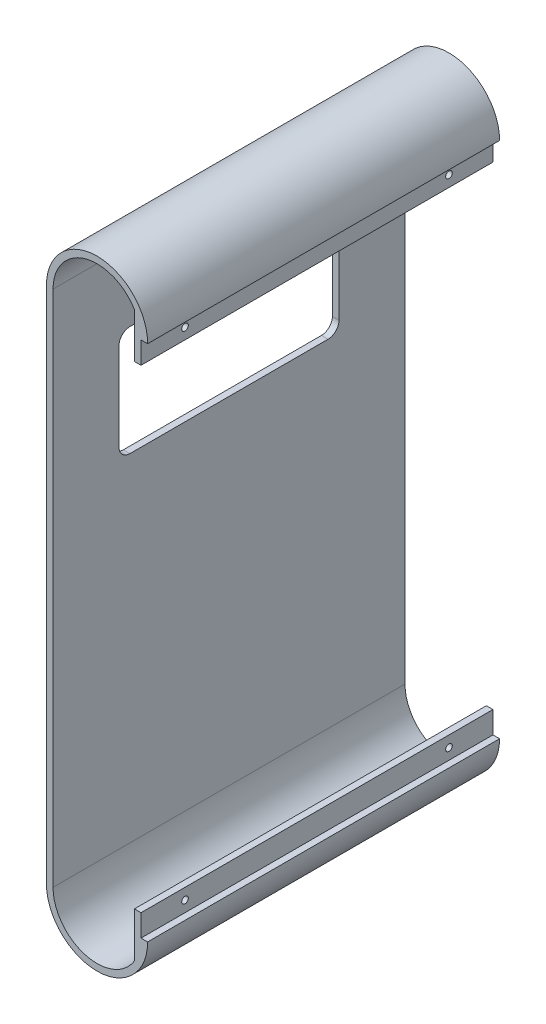
from build123d import *

# Parameters (mm, degrees)
BOSS_EXTRUDE1_DEPTH = 160
SKETCH5_W           = 3
SKETCH5_H           = 21.357816692
BOSS_EXTRUDE4_DEPTH = 160
SKETCH7_R           = 1.5
CUT_EXTRUDE2_DEPTH  = 7
CUT_EXTRUDE3_DEPTH  = 3


with BuildPart() as part:
    # Sketch1 → Boss-Extrude1 (new body)
    with BuildSketch(Plane.XY):
        with BuildLine():
            Line((-40, -75), (-40, 160.5))
            ThreePointArc((-40, 160.5), (-20, 180.5), (0, 160.5))
            Line((0, 160.5), (3, 160.5))
            ThreePointArc((3, 160.5), (-20, 183.5), (-43, 160.5))
            Line((-43, 160.5), (-43, -75))
            ThreePointArc((-43, -75), (-20, -98), (3, -75))
            Line((3, -75), (0, -75))
            ThreePointArc((0, -75), (-20, -95), (-40, -75))
        make_face()
    extrude(amount=-BOSS_EXTRUDE1_DEPTH)

    # Sketch5 → Boss-Extrude4 (add)
    with BuildSketch(Plane(origin=(0, 0, -160), x_dir=(-1, 0, 0), z_dir=(0, 0, -1))):
        with Locations((1.5, -75.678908346)):
            Rectangle(SKETCH5_W, SKETCH5_H)
        with Locations((1.5, 161.178908346)):
            Rectangle(SKETCH5_W, SKETCH5_H)
    extrude(amount=-BOSS_EXTRUDE4_DEPTH)

    # Sketch7 → Cut-Extrude2 (cut, through all)
    with BuildSketch(Plane.ZY.offset(3)):
        with Locations((-140, -70)):
            Circle(SKETCH7_R)
        with Locations((-20, -70)):
            Circle(SKETCH7_R)
        with Locations((-20, 155.5)):
            Circle(SKETCH7_R)
        with Locations((-140, 155.5)):
            Circle(SKETCH7_R)
    extrude(amount=-CUT_EXTRUDE2_DEPTH, mode=Mode.SUBTRACT)

    # Sketch8 → Cut-Extrude3 (cut)
    with BuildSketch(Plane.ZY.offset(43)):
        with BuildLine():
            Line((-125, 128.257283518), (-35, 128.257283518))
            ThreePointArc((-35, 128.257283518), (-31.464466094, 126.792817424), (-30, 123.257283518))
            Line((-30, 123.257283518), (-30, 83.257283518))
            ThreePointArc((-30, 83.257283518), (-31.464466094, 79.721749612), (-35, 78.257283518))
            Line((-35, 78.257283518), (-125, 78.257283518))
            ThreePointArc((-125, 78.257283518), (-128.535533906, 79.721749612), (-130, 83.257283518))
            Line((-130, 83.257283518), (-130, 123.257283518))
            ThreePointArc((-130, 123.257283518), (-128.535533906, 126.792817424), (-125, 128.257283518))
        make_face()
    extrude(amount=-CUT_EXTRUDE3_DEPTH, mode=Mode.SUBTRACT)


solid = part.part
